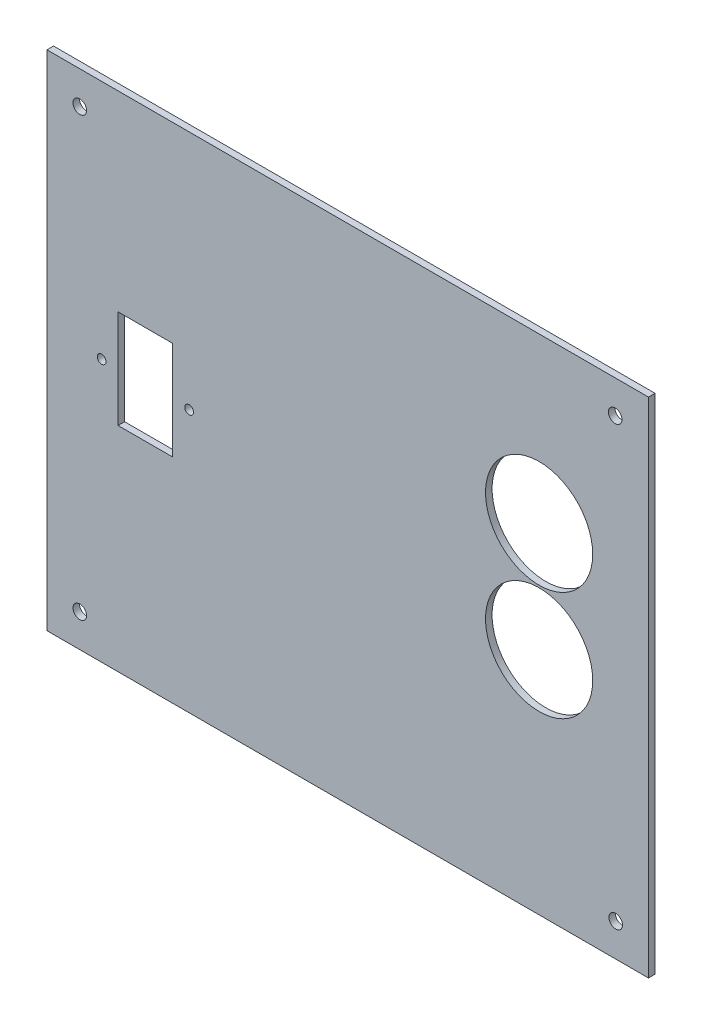
from build123d import *

# Parameters (mm, degrees)
CROQUIS1_W              = 275
CROQUIS1_H              = 230
CROQUIS1_R              = 3.1
SALIENTE_EXTRUIR1_DEPTH = 3
CROQUIS2_R              = 24.5
CORTAR_EXTRUIR1_DEPTH   = 4
CROQUIS3_R              = 2
CROQUIS3_W              = 25
CROQUIS3_H              = 45
CORTAR_EXTRUIR2_DEPTH   = 4


with BuildPart() as part:
    # Croquis1 → Saliente-Extruir1 (new body)
    with BuildSketch(Plane.XY):
        Rectangle(CROQUIS1_W, CROQUIS1_H)
        with Locations((-122.5, 100)):
            Circle(CROQUIS1_R, mode=Mode.SUBTRACT)
        with Locations((122.275174875, 100)):
            Circle(CROQUIS1_R, mode=Mode.SUBTRACT)
        with Locations((-122.5, -100)):
            Circle(CROQUIS1_R, mode=Mode.SUBTRACT)
        with Locations((122.5, -100)):
            Circle(CROQUIS1_R, mode=Mode.SUBTRACT)
    extrude(amount=SALIENTE_EXTRUIR1_DEPTH)

    # Croquis2 → Cortar-Extruir1 (cut, through all)
    with BuildSketch(Plane.XY.offset(3)):
        with Locations((87.5, 40)):
            Circle(CROQUIS2_R)
        with Locations((87.5, -10)):
            Circle(CROQUIS2_R)
    extrude(amount=-CORTAR_EXTRUIR1_DEPTH, mode=Mode.SUBTRACT)

    # Croquis3 → Cortar-Extruir2 (cut, through all)
    with BuildSketch(Plane.XY.offset(3)):
        with Locations((-112.5, 5)):
            Circle(CROQUIS3_R)
        with Locations((-72.5, 5)):
            Circle(CROQUIS3_R)
        with Locations((-92.5, 5)):
            Rectangle(CROQUIS3_W, CROQUIS3_H)
    extrude(amount=-CORTAR_EXTRUIR2_DEPTH, mode=Mode.SUBTRACT)


solid = part.part
